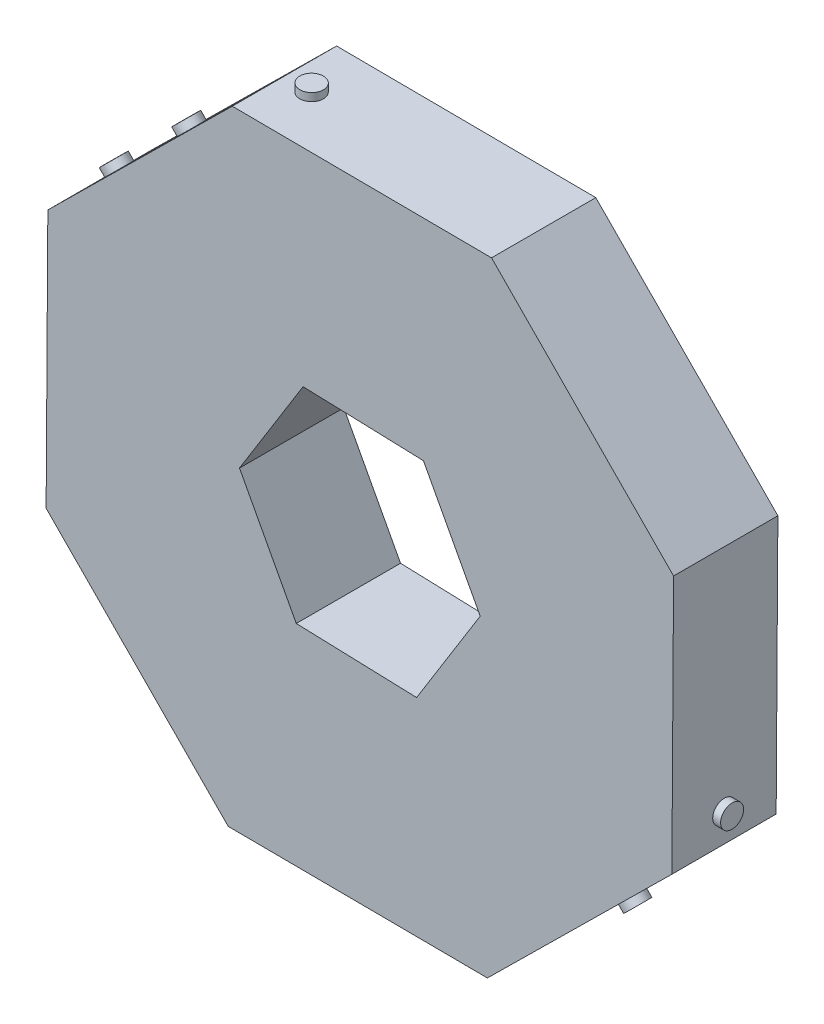
from build123d import *

# Parameters (mm, degrees)
BOSS_EXTRUDE1_DEPTH = 6.35
SKETCH2_R           = 0.72
BOSS_EXTRUDE2_DEPTH = 0.48
SKETCH3_R           = 0.72
BOSS_EXTRUDE3_DEPTH = 0.48
SKETCH4_R           = 0.72
BOSS_EXTRUDE4_DEPTH = 0.48
SKETCH5_R           = 0.7
BOSS_EXTRUDE5_DEPTH = 0.48
SKETCH6_R           = 0.7
BOSS_EXTRUDE6_DEPTH = 0.48
SKETCH7_R           = 0.7
BOSS_EXTRUDE7_DEPTH = 0.48
SKETCH8_R           = 0.7
BOSS_EXTRUDE8_DEPTH = 0.48
CUT_EXTRUDE1_DEPTH  = 7.35


with BuildPart() as part:
    # Sketch1 → Boss-Extrude1 (new body)
    with BuildSketch(Plane.XY):
        Polygon((-7.764898793, 19.101651031), (-18.997519567, 8.016294384), (-19.101651031, -7.764898793), (-8.016294384, -18.997519567), (7.764898793, -19.101651031), (18.997519567, -8.016294384), (19.101651031, 7.764898793), (8.016294384, 18.997519567), align=None)
    extrude(amount=BOSS_EXTRUDE1_DEPTH)

    # Sketch2 → Boss-Extrude2 (add)
    with BuildSketch(Plane(origin=(0.125697795, 19.049585299, 0), x_dir=(0.999978231, -0.006598309, 0), z_dir=(0.006598309, 0.999978231, 0))):
        with Locations((-6.239768363, -3.175)):
            Circle(SKETCH2_R)
    extrude(amount=BOSS_EXTRUDE2_DEPTH)

    # Sketch3 → Boss-Extrude3 (add)
    with BuildSketch(Plane(origin=(-13.38120918, 13.558972707, 0), x_dir=(0.711757097, 0.702425679, 0), z_dir=(-0.702425679, 0.711757097, 0))):
        with Locations((-6.239768363, -3.175)):
            Circle(SKETCH3_R)
        with Locations((-0.039768363, -3.175)):
            Circle(SKETCH3_R)
    extrude(amount=BOSS_EXTRUDE3_DEPTH)

    # Sketch4 → Boss-Extrude4 (add)
    with BuildSketch(Plane(origin=(-19.049585299, 0.125697795, 0), x_dir=(0, 0, 1), z_dir=(-0.999978231, 0.006598309, 0))):
        with Locations((3.175, -6.239768363)):
            Circle(SKETCH4_R)
        with Locations((3.175, 0.000224237)):
            Circle(SKETCH4_R)
        with Locations((3.175, 6.240224237)):
            Circle(SKETCH4_R)
    extrude(amount=BOSS_EXTRUDE4_DEPTH)

    # Sketch5 → Boss-Extrude5 (add)
    with BuildSketch(Plane(origin=(-13.558972707, -13.38120918, 0), x_dir=(0, 0, 1), z_dir=(-0.711757097, -0.702425679, 0))):
        with Locations((3.175, -6.239768363)):
            Circle(SKETCH5_R)
        with Locations((3.175, 6.160231637)):
            Circle(SKETCH5_R)
    extrude(amount=BOSS_EXTRUDE5_DEPTH)

    # Sketch6 → Boss-Extrude6 (add)
    with BuildSketch(Plane(origin=(-0.125697795, -19.049585299, 0), x_dir=(-0.999978231, 0.006598309, 0), z_dir=(-0.006598309, -0.999978231, 0))):
        with Locations((-0.039768363, -3.175)):
            Circle(SKETCH6_R)
        with Locations((6.160231637, -3.175)):
            Circle(SKETCH6_R)
    extrude(amount=BOSS_EXTRUDE6_DEPTH)

    # Sketch7 → Boss-Extrude7 (add)
    with BuildSketch(Plane(origin=(13.38120918, -13.558972707, 0), x_dir=(-0.711757097, -0.702425679, 0), z_dir=(0.702425679, -0.711757097, 0))):
        with Locations((-0.039768363, -3.175)):
            Circle(SKETCH7_R)
    extrude(amount=BOSS_EXTRUDE7_DEPTH)

    # Sketch8 → Boss-Extrude8 (add)
    with BuildSketch(Plane(origin=(19.049585299, -0.125697795, 0), x_dir=(0, 0, -1), z_dir=(0.999978231, -0.006598309, 0))):
        with Locations((-3.175, -6.160231637)):
            Circle(SKETCH8_R)
    extrude(amount=BOSS_EXTRUDE8_DEPTH)

    # Sketch9 → Cut-Extrude1 (cut, through all)
    with BuildSketch(Plane(origin=(0, 0, 0), x_dir=(-1, 0, 0), z_dir=(0, 0, -1))):
        Polygon((-3.872311644, 6.226438458), (-7.328409701, -0.240301026), (-3.456098057, -6.466739484), (3.872311644, -6.226438458), (7.328409701, 0.240301026), (3.456098057, 6.466739484), align=None)
    extrude(amount=-CUT_EXTRUDE1_DEPTH, mode=Mode.SUBTRACT)


solid = part.part
